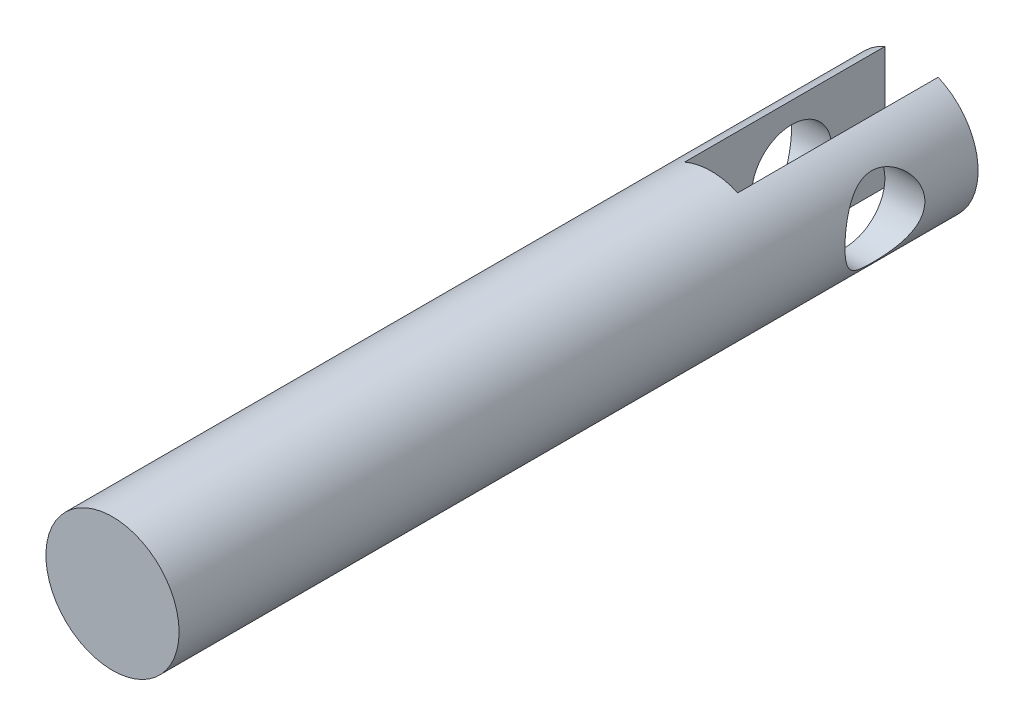
from build123d import *

# Parameters (mm, degrees)
SKETCH1_R               = 10
BOSS_EXTRUDE1_DEPTH     = 120
CUT_EXTRUDE3_DEPTH      = 40
CUT_EXTRUDE3_DEPTH_BACK = 40
SKETCH4_R               = 6
CUT_EXTRUDE4_DEPTH      = 4
CUT_EXTRUDE4_DEPTH_BACK = 4
SKETCH5_W               = 23.593926408
SKETCH5_H               = 33.705609154


with BuildPart() as part:
    # Sketch1 → Boss-Extrude1 (new body)
    with BuildSketch(Plane(origin=(0, 0, 0), x_dir=(0, 1, 0), z_dir=(0, 0, 1))):
        Circle(SKETCH1_R)
    extrude(amount=BOSS_EXTRUDE1_DEPTH)

    # Sketch4 → Cut-Extrude3 (cut, two sides: drawn at the far end of the back side and taken through both)
    with BuildSketch(Plane.YZ.offset(-CUT_EXTRUDE3_DEPTH_BACK)):
        with Locations((0, 14)):
            Circle(SKETCH4_R)
    extrude(amount=CUT_EXTRUDE3_DEPTH + CUT_EXTRUDE3_DEPTH_BACK, mode=Mode.SUBTRACT)

    # Sketch5 → Cut-Extrude4 (cut, two sides: drawn at the far end of the back side and taken through both)
    with BuildSketch(Plane.YZ.offset(-CUT_EXTRUDE4_DEPTH_BACK)):
        with Locations((0.674112183, 13.2334673)):
            Rectangle(SKETCH5_W, SKETCH5_H)
    extrude(amount=CUT_EXTRUDE4_DEPTH + CUT_EXTRUDE4_DEPTH_BACK, mode=Mode.SUBTRACT)


solid = part.part
